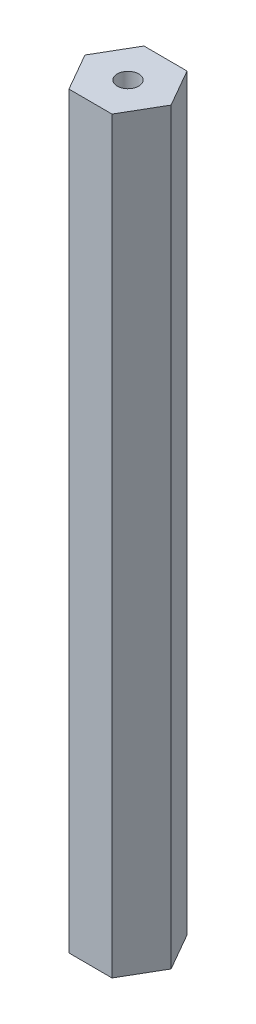
from build123d import *

# Parameters (mm, degrees)
SKETCH1_R           = 1.27
BOSS_EXTRUDE1_DEPTH = 88.9


with BuildPart() as part:
    # Sketch1 → Boss-Extrude1 (new body)
    with BuildSketch(Plane(origin=(0, 0, 0), x_dir=(1, 0, 0), z_dir=(0, 1, 0))):
        Polygon((2.551999169, -4.453238549), (5.132617297, -0.016523164), (2.580618128, 4.436715385), (-2.551999169, 4.453238549), (-5.132617297, 0.016523164), (-2.580618128, -4.436715385), align=None)
        Circle(SKETCH1_R, mode=Mode.SUBTRACT)
    extrude(amount=BOSS_EXTRUDE1_DEPTH)


solid = part.part
